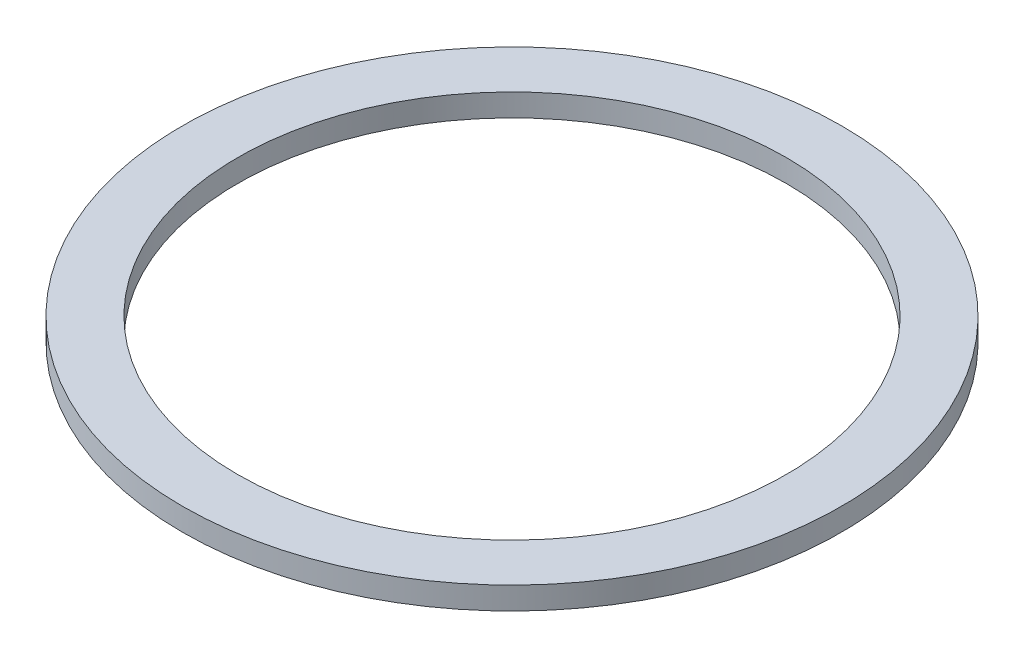
from build123d import *

# Parameters (mm, degrees)
SKETCH1_R           = 14.65
SKETCH1_R_2         = 12.2
BOSS_EXTRUDE1_DEPTH = 1


with BuildPart() as part:
    # Sketch1 → Boss-Extrude1 (new body)
    with BuildSketch(Plane(origin=(0, 0, 0), x_dir=(1, 0, 0), z_dir=(0, 1, 0))):
        Circle(SKETCH1_R)
        Circle(SKETCH1_R_2, mode=Mode.SUBTRACT)
    extrude(amount=BOSS_EXTRUDE1_DEPTH)


solid = part.part
